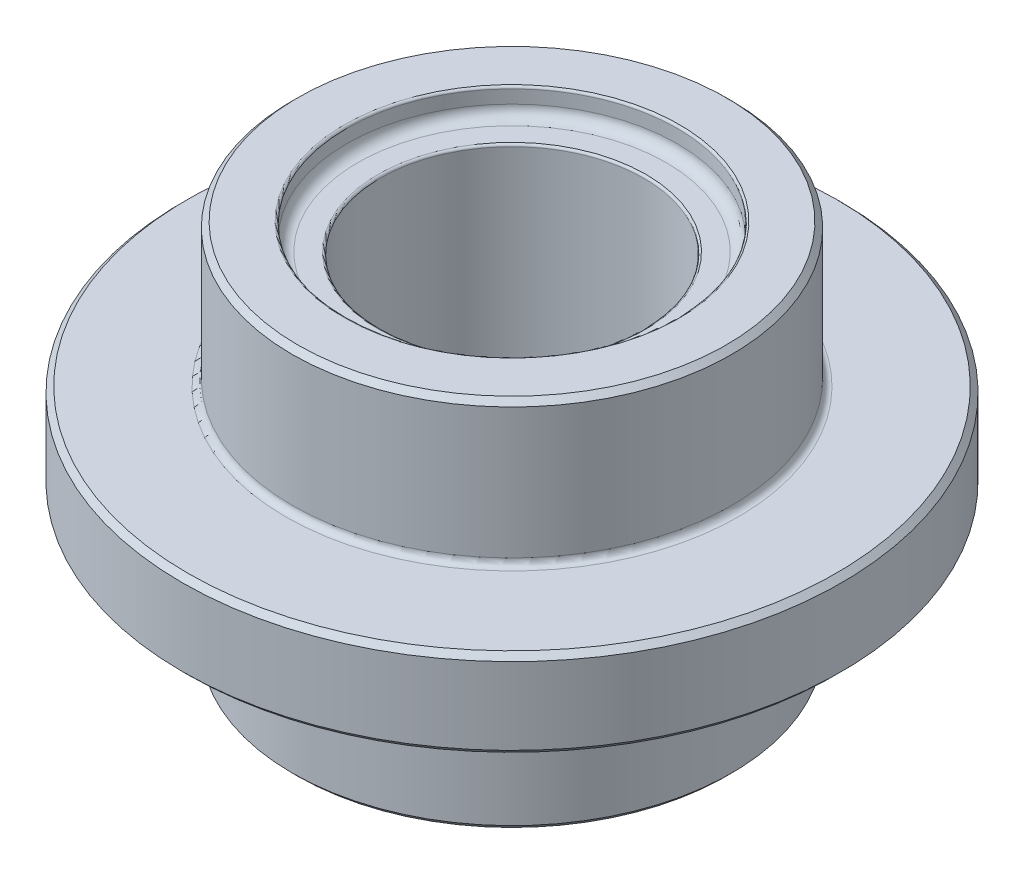
from build123d import *

# Parameters (mm, degrees)
SKETCH1_R               = 30
EXTRUDE1_DEPTH          = 4
EXTRUDE1_DEPTH_BACK     = 4
SKETCH2_R               = 20
EXTRUDE2_DEPTH          = 17
EXTRUDE2_DEPTH_BACK     = 17
SKETCH3_R               = 12
CUT_EXTRUDE1_DEPTH      = 18
CUT_EXTRUDE1_DEPTH_BACK = 18
SKETCH4_R               = 15.05
CUT_EXTRUDE2_DEPTH      = 2.4
CHAMFER1_SIZE           = 0.5
FILLET1_R               = 0.6
FILLET2_R               = 0.2
FILLET3_R               = 1


with BuildPart() as part:
    # Sketch1 → Extrude1 (new body, two sides)
    with BuildSketch(Plane(origin=(0, 0, 0), x_dir=(1, 0, 0), z_dir=(0, 1, 0))) as extrude1_sk:
        Circle(SKETCH1_R)
    extrude(amount=EXTRUDE1_DEPTH)
    extrude(extrude1_sk.sketch, amount=-EXTRUDE1_DEPTH_BACK)

    # Sketch2 → Extrude2 (add, two sides)
    with BuildSketch(Plane(origin=(0, 0, 0), x_dir=(1, 0, 0), z_dir=(0, 1, 0))) as extrude2_sk:
        Circle(SKETCH2_R)
    extrude(amount=EXTRUDE2_DEPTH)
    extrude(extrude2_sk.sketch, amount=-EXTRUDE2_DEPTH_BACK)

    # Sketch3 → Cut-Extrude1 (cut, two sides)
    with BuildSketch(Plane(origin=(0, 0, 0), x_dir=(1, 0, 0), z_dir=(0, 1, 0))) as cut_extrude1_sk:
        Circle(SKETCH3_R)
    extrude(amount=CUT_EXTRUDE1_DEPTH, mode=Mode.SUBTRACT)
    extrude(cut_extrude1_sk.sketch, amount=-CUT_EXTRUDE1_DEPTH_BACK, mode=Mode.SUBTRACT)

    # Sketch4 → Cut-Extrude2 (cut)
    with BuildSketch(Plane(origin=(0, 17, 0), x_dir=(-1, 0, 0), z_dir=(0, 1, 0))):
        Circle(SKETCH4_R)
    extrude(amount=-CUT_EXTRUDE2_DEPTH, mode=Mode.SUBTRACT)

    # Chamfer1
    chamfer1_edges = [part.edges().sort_by_distance(p)[0] for p in [
        (-12, -17, 0),
        (-30, -4, 0),
        (-30, 4, 0),
        (-20, -17, 0),
        (-20, 17, 0),
    ]]
    chamfer(chamfer1_edges, length=CHAMFER1_SIZE)

    # Fillet1
    fillet1_edges = [part.edges().sort_by_distance(p)[0] for p in [
        (-20, -4, 0),
        (-20, 4, 0),
    ]]
    fillet(fillet1_edges, radius=FILLET1_R)

    # Fillet2
    fillet2_edges = [part.edges().sort_by_distance(p)[0] for p in [
        (15.05, 17, 0),
        (-12, 14.6, 0),
    ]]
    fillet(fillet2_edges, radius=FILLET2_R)

    # Fillet3
    fillet3_edges = [part.edges().sort_by_distance(p)[0] for p in [
        (15.05, 14.6, 0),
    ]]
    fillet(fillet3_edges, radius=FILLET3_R)


solid = part.part
